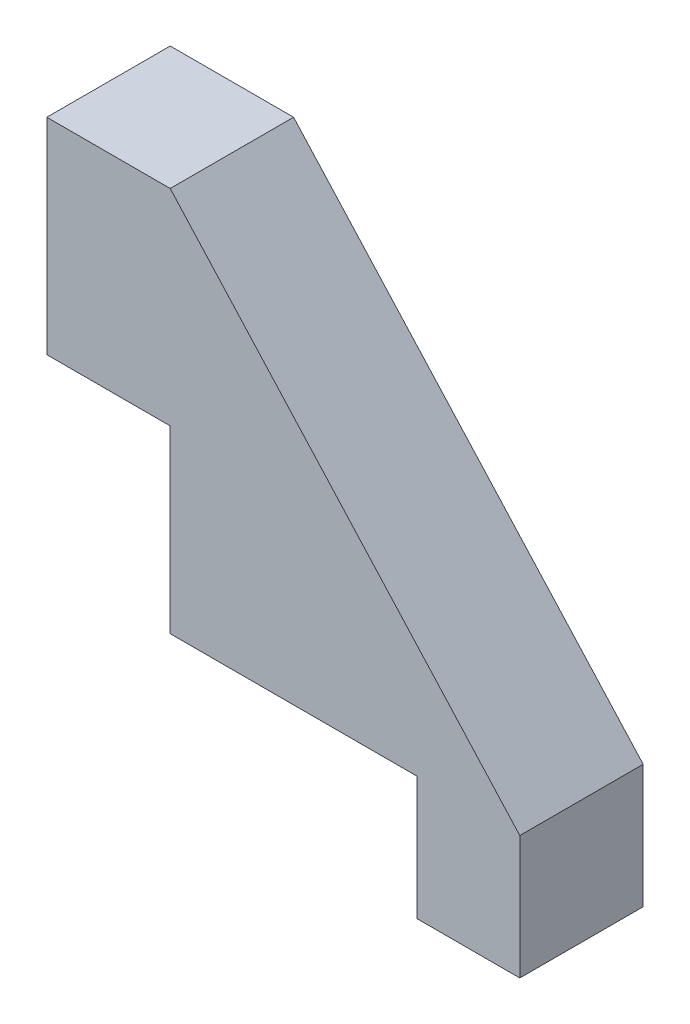
from build123d import *

# Parameters (mm, degrees)
BOSS_EXTRUDE1_DEPTH = 6


with BuildPart() as part:
    # Sketch1 → Boss-Extrude1 (new body)
    with BuildSketch(Plane.XY):
        Polygon((0, 0), (0, 8.75), (-6, 8.75), (-6, 18.75), (0, 18.75), (17, 0), (17, -6), (12, -6), (12, 0), align=None)
    extrude(amount=BOSS_EXTRUDE1_DEPTH)


solid = part.part
